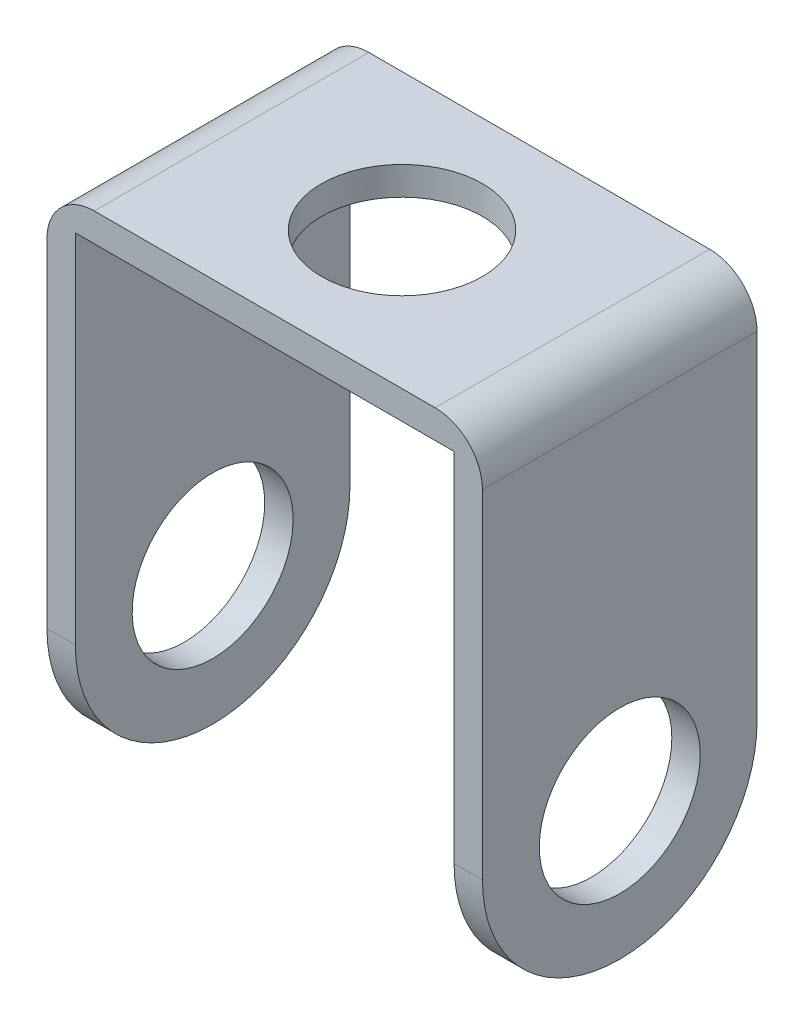
from build123d import *

# Parameters (mm, degrees)
BOSS_EXTRUDE1_DEPTH = 7.25
CUT_EXTRUDE1_DEPTH  = 50
CUT_EXTRUDE2_DEPTH  = 50
SKETCH2_4_R         = 2.125
CUT_EXTRUDE3_DEPTH  = 50
SKETCH6_R           = 2.125
CUT_EXTRUDE4_DEPTH  = 50


with BuildPart() as part:
    # Sketch1 → Boss-Extrude1 (new body)
    with BuildSketch(Plane.XY):
        with BuildLine():
            Line((0, 0), (0, 12.55))
            ThreePointArc((0, 12.55), (0.366116524, 13.433883476), (1.25, 13.8))
            Line((1.25, 13.8), (10.25, 13.8))
            ThreePointArc((10.25, 13.8), (11.133883476, 13.433883476), (11.5, 12.55))
            Line((11.5, 12.55), (11.5, 0))
            Line((11.5, 0), (10.75, 0))
            Line((10.75, 0), (10.75, 13.05))
            Line((10.75, 13.05), (0.75, 13.05))
            Line((0.75, 13.05), (0.75, 0))
            Line((0.75, 0), (0, 0))
        make_face()
    extrude(amount=BOSS_EXTRUDE1_DEPTH)

    # Sketch2 → Cut-Extrude1 (cut, symmetric)
    with BuildSketch(Plane.ZY):
        with BuildLine():
            Line((0, 0), (3.625, 0))
            ThreePointArc((3.625, 0), (1.061737918, 1.061737918), (0, 3.625))
            Line((0, 3.625), (0, 0))
        make_face()
    extrude(amount=CUT_EXTRUDE1_DEPTH, both=True, mode=Mode.SUBTRACT)

    # Sketch2_3 → Cut-Extrude2 (cut, symmetric)
    with BuildSketch(Plane.ZY):
        with BuildLine():
            ThreePointArc((7.25, 3.625), (6.188262082, 1.061737918), (3.625, 0))
            Line((3.625, 0), (7.25, 0))
            Line((7.25, 0), (7.25, 3.625))
        make_face()
    extrude(amount=CUT_EXTRUDE2_DEPTH, both=True, mode=Mode.SUBTRACT)

    # Sketch2_4 → Cut-Extrude3 (cut, symmetric)
    with BuildSketch(Plane.ZY):
        with Locations((3.625, 3.625)):
            Circle(SKETCH2_4_R)
    extrude(amount=CUT_EXTRUDE3_DEPTH, both=True, mode=Mode.SUBTRACT)

    # Sketch6 → Cut-Extrude4 (cut, symmetric)
    with BuildSketch(Plane(origin=(0, 13.8, 0), x_dir=(1, 0, 0), z_dir=(0, 1, 0))):
        with Locations((5.75, -3.625)):
            Circle(SKETCH6_R)
    extrude(amount=CUT_EXTRUDE4_DEPTH, both=True, mode=Mode.SUBTRACT)


solid = part.part
